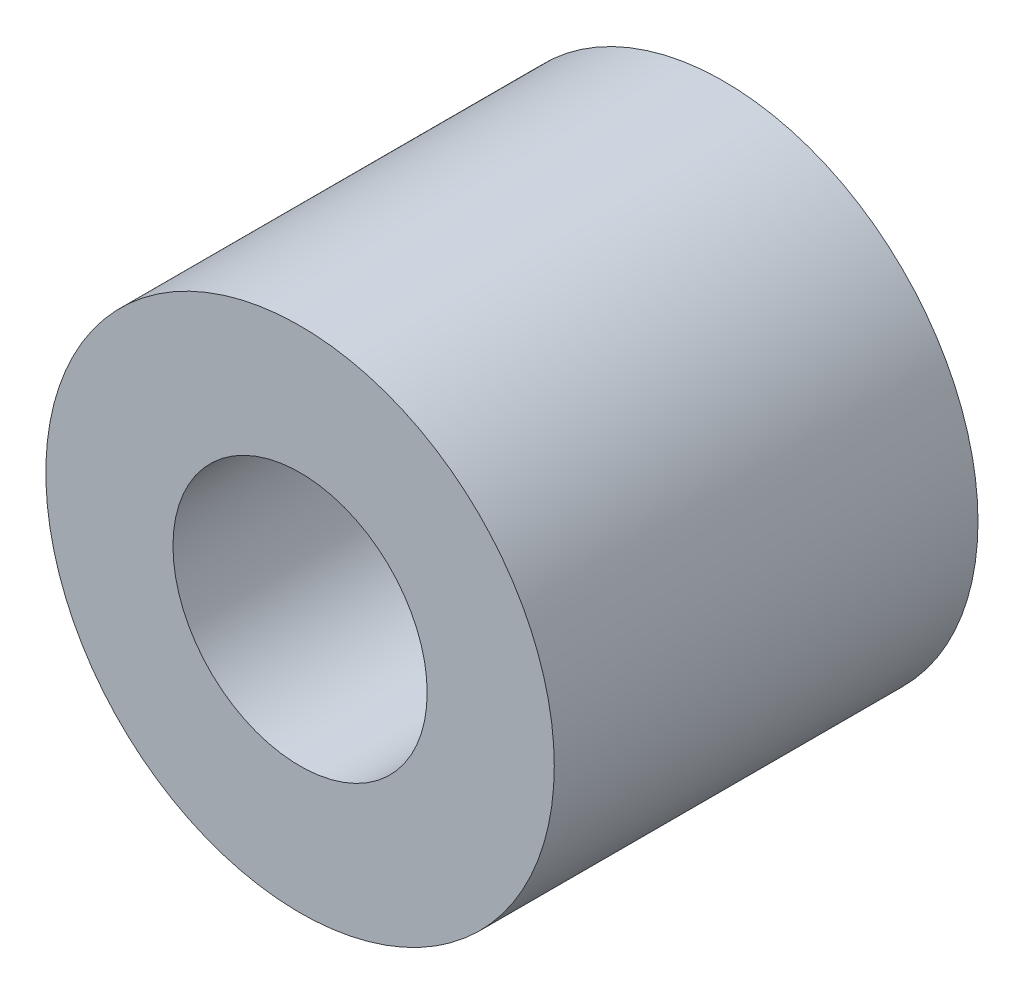
from build123d import *

# Parameters (mm, degrees)
CROQUIS1_R              = 3
CROQUIS1_R_2            = 1.5
SALIENTE_EXTRUIR1_DEPTH = 5


with BuildPart() as part:
    # Croquis1 → Saliente-Extruir1 (new body)
    with BuildSketch(Plane.XY):
        Circle(CROQUIS1_R)
        Circle(CROQUIS1_R_2, mode=Mode.SUBTRACT)
    extrude(amount=SALIENTE_EXTRUIR1_DEPTH)


solid = part.part
